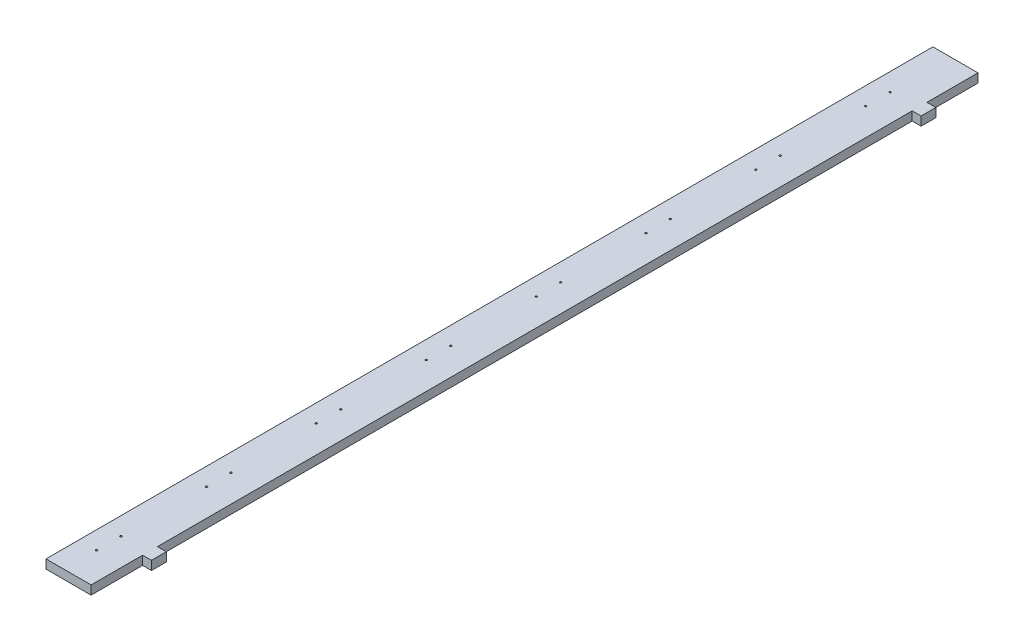
from build123d import *

# Parameters (mm, degrees)
SKETCH1_W           = 61
SKETCH1_H           = 1200
BOSS_EXTRUDE1_DEPTH = 12
SKETCH2_R           = 1.25
CUT_EXTRUDE1_DEPTH  = 20
SKETCH3_W           = 23.420452048
SKETCH3_H           = 20
BOSS_EXTRUDE2_DEPTH = 12


with BuildPart() as part:
    # Sketch1 → Boss-Extrude1 (new body)
    with BuildSketch(Plane(origin=(0, 0, 0), x_dir=(1, 0, 0), z_dir=(0, 1, 0))):
        with Locations((30.5, 600)):
            Rectangle(SKETCH1_W, SKETCH1_H)
    extrude(amount=BOSS_EXTRUDE1_DEPTH)

    # Sketch2 → Cut-Extrude1 (cut)
    with BuildSketch(Plane(origin=(0, 12, 0), x_dir=(1, 0, 0), z_dir=(0, 1, 0))):
        with Locations((24.140899916, 77.395)):
            Circle(SKETCH2_R)
        with Locations((24.140899916, 44.395)):
            Circle(SKETCH2_R)
        with Locations((24.140899916, 226.045)):
            Circle(SKETCH2_R)
        with Locations((24.140899916, 193.045)):
            Circle(SKETCH2_R)
        with Locations((24.140899916, 374.695)):
            Circle(SKETCH2_R)
        with Locations((24.140899916, 341.695)):
            Circle(SKETCH2_R)
        with Locations((24.140899916, 523.345)):
            Circle(SKETCH2_R)
        with Locations((24.140899916, 490.345)):
            Circle(SKETCH2_R)
        with Locations((24.140899916, 671.995)):
            Circle(SKETCH2_R)
        with Locations((24.140899916, 638.995)):
            Circle(SKETCH2_R)
        with Locations((24.140899916, 820.645)):
            Circle(SKETCH2_R)
        with Locations((24.140899916, 787.645)):
            Circle(SKETCH2_R)
        with Locations((24.140899916, 969.295)):
            Circle(SKETCH2_R)
        with Locations((24.140899916, 936.295)):
            Circle(SKETCH2_R)
        with Locations((24.140899916, 1117.945)):
            Circle(SKETCH2_R)
        with Locations((24.140899916, 1084.945)):
            Circle(SKETCH2_R)
    extrude(amount=-CUT_EXTRUDE1_DEPTH, mode=Mode.SUBTRACT)

    # Sketch3 → Boss-Extrude2 (add)
    with BuildSketch(Plane(origin=(0, 12, 0), x_dir=(1, 0, 0), z_dir=(0, 1, 0))):
        with Locations((61.289773976, 79.7)):
            Rectangle(SKETCH3_W, SKETCH3_H)
        with Locations((61.289773976, 1120.95)):
            Rectangle(SKETCH3_W, SKETCH3_H)
    extrude(amount=-BOSS_EXTRUDE2_DEPTH)


solid = part.part
